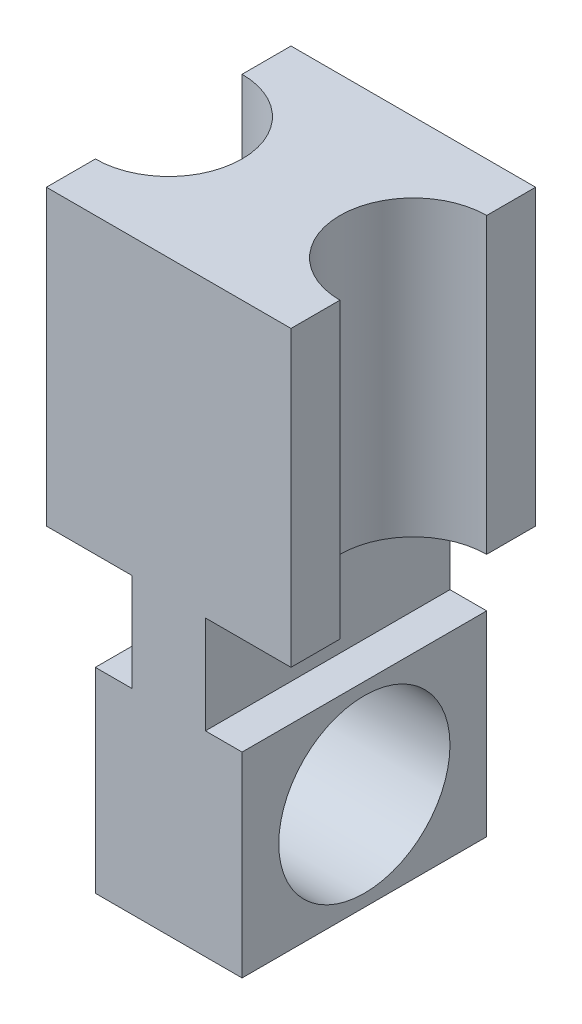
from build123d import *

# Parameters (mm, degrees)
SKETCH1_W               = 127
SKETCH1_H               = 127
BOSS_EXTRUDE1_DEPTH     = 152.4
SKETCH2_R               = 31.172448383
SKETCH2_R_2             = 38.1
CUT_EXTRUDE1_DEPTH      = 152.4
CUT_EXTRUDE1_DEPTH_BACK = 152.4
SKETCH3_W               = 127
SKETCH3_H               = 127
BOSS_EXTRUDE2_DEPTH     = 152.4
CUT_EXTRUDE_THIN3_DEPTH = 152.4
SKETCH6_R               = 44.45
CUT_EXTRUDE6_DEPTH      = 249.428
CUT_EXTRUDE6_DEPTH_BACK = 249.428
SKETCH7_W               = 25.4
SKETCH7_H               = 101.6
CUT_EXTRUDE8_DEPTH      = 143.256
SKETCH9_R               = 38.1
CUT_EXTRUDE9_DEPTH      = 152.4


with BuildPart() as part:
    # Sketch1 → Boss-Extrude1 (new body)
    with BuildSketch(Plane(origin=(0, 0, 0), x_dir=(1, 0, 0), z_dir=(0, 1, 0))):
        with Locations((63.5, 63.5)):
            Rectangle(SKETCH1_W, SKETCH1_H)
    extrude(amount=BOSS_EXTRUDE1_DEPTH)

    # Sketch2 → Cut-Extrude1 (cut, two sides)
    with BuildSketch(Plane(origin=(0, 0, 0), x_dir=(1, 0, 0), z_dir=(0, 1, 0))) as cut_extrude1_sk:
        with Locations((0, 63.5)):
            Circle(SKETCH2_R)
        with Locations((127, 63.5)):
            Circle(SKETCH2_R_2)
    extrude(amount=CUT_EXTRUDE1_DEPTH, mode=Mode.SUBTRACT)
    extrude(cut_extrude1_sk.sketch, amount=-CUT_EXTRUDE1_DEPTH_BACK, mode=Mode.SUBTRACT)

    # Sketch3 → Boss-Extrude2 (add)
    with BuildSketch(Plane(origin=(0, 0, 0), x_dir=(1, 0, 0), z_dir=(0, 1, 0))):
        with Locations((63.5, 63.5)):
            Rectangle(SKETCH3_W, SKETCH3_H)
    extrude(amount=-BOSS_EXTRUDE2_DEPTH)

    # Sketch5 → Cut-Extrude-Thin3 (cut)
    with BuildSketch(Plane(origin=(0, 0, -129.54), x_dir=(-1, 0, 0), z_dir=(0, 0, -1))):
        Polygon((-127, 0), (-82.55, 0), (-82.55, -50.8), (-127, -50.8), (-127, -48.26), (-85.09, -48.26), (-85.09, -2.54), (-127, -2.54), align=None)
        Polygon((0, -50.8), (-44.45, -50.8), (-44.45, 0), (0, 0), (0, -2.54), (-41.91, -2.54), (-41.91, -48.26), (0, -48.26), align=None)
    extrude(amount=-CUT_EXTRUDE_THIN3_DEPTH, mode=Mode.SUBTRACT)


with BuildPart() as body_2:
    # of the pieces the cut leaves, the one that is kept (cut_extrude_thin3_keep)
    add(part.part.solids().sort_by_distance((0, 152.4, 0))[0])

    # Sketch6 → Cut-Extrude6 (cut, two sides)
    with BuildSketch(Plane(origin=(0, 0, 0), x_dir=(0, 0, -1), z_dir=(1, 0, 0))) as cut_extrude6_sk:
        with Locations(Location((63.5, -101.6, 0), (0, 0, 180))):
            Circle(SKETCH6_R)
    extrude(amount=CUT_EXTRUDE6_DEPTH, mode=Mode.SUBTRACT)
    extrude(cut_extrude6_sk.sketch, amount=-CUT_EXTRUDE6_DEPTH_BACK, mode=Mode.SUBTRACT)

    # Sketch7 → Cut-Extrude8 (cut)
    with BuildSketch(Plane(origin=(0, 0, -129.54), x_dir=(-1, 0, 0), z_dir=(0, 0, -1))):
        with Locations((-114.3, -101.6)):
            Rectangle(SKETCH7_W, SKETCH7_H)
        with Locations((-12.7, -101.6)):
            Rectangle(SKETCH7_W, SKETCH7_H)
    extrude(amount=-CUT_EXTRUDE8_DEPTH, mode=Mode.SUBTRACT)

    # Sketch9 → Cut-Extrude9 (cut)
    with BuildSketch(Plane(origin=(0, 152.4, 0), x_dir=(1, 0, 0), z_dir=(0, 1, 0))):
        with Locations((0, 63.5)):
            Circle(SKETCH9_R)
    extrude(amount=-CUT_EXTRUDE9_DEPTH, mode=Mode.SUBTRACT)


solid = body_2.part
